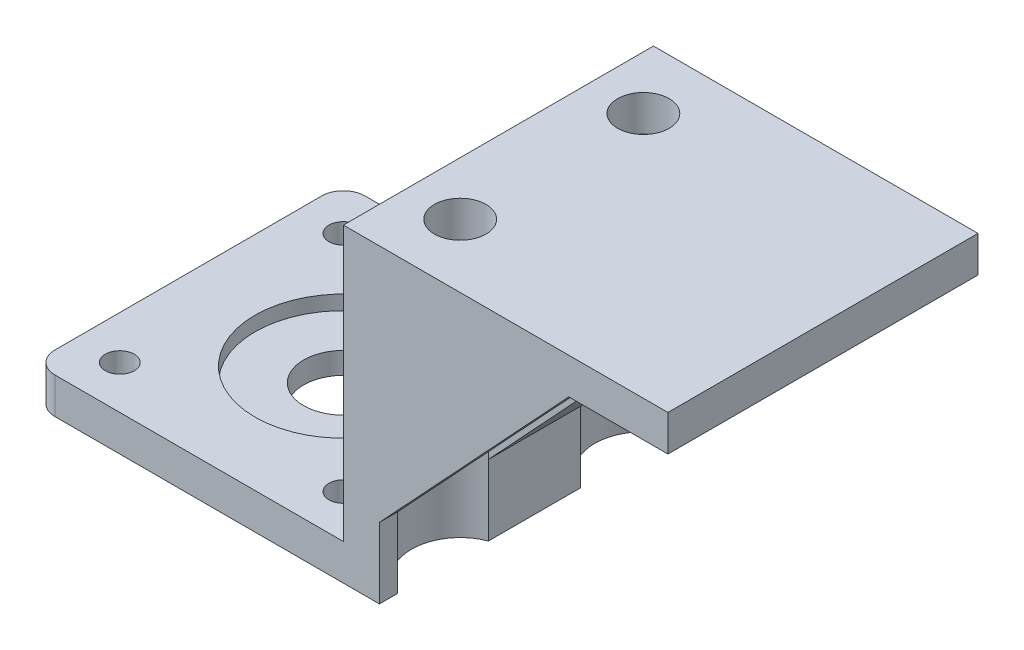
from build123d import *

# Parameters (mm, degrees)
SKETCH1_W                 = 43
SKETCH1_H                 = 43
BOSS_EXTRUDE1_DEPTH       = 5
FILLET1_R                 = 3
F_4_0MM_DOWEL_HOLE1_D     = 4
F_4_0MM_DOWEL_HOLE1_DEPTH = 10
F_4_0MM_DOWEL_HOLE1_TIP   = 1.201721238
SKETCH5_R                 = 5.5
CUT_EXTRUDE1_DEPTH        = 5
SKETCH6_W                 = 5
SKETCH6_H                 = 43
BOSS_EXTRUDE2_DEPTH       = 38
BOSS_EXTRUDE2_DEPTH_BACK  = 5
CUT_EXTRUDE4_START        = -5
SKETCH11_R                = 12.25
CUT_EXTRUDE4_DEPTH        = 2
SKETCH12_W                = 43
SKETCH12_H                = 5
BOSS_EXTRUDE3_DEPTH       = 40
SKETCH13_R                = 3.571875
CUT_EXTRUDE5_DEPTH        = 10
SKETCH15_R                = 6.75
CUT_EXTRUDE6_DEPTH        = 38
BOSS_EXTRUDE4_DEPTH       = 2.5
LPATTERN1_COUNT           = 3
LPATTERN1_PITCH           = 20.25
BOSS_EXTRUDE5_DEPTH       = 5.141078
BOSS_EXTRUDE5_DEPTH_BACK  = 7.641078
BOSS_EXTRUDE6_DEPTH       = 5


with BuildPart() as part:
    # Sketch1 → Boss-Extrude1 (new body)
    with BuildSketch(Plane(origin=(0, 0, 0), x_dir=(1, 0, 0), z_dir=(0, 1, 0))):
        with Locations((21.5, -22.047500095)):
            Rectangle(SKETCH1_W, SKETCH1_H)
    extrude(amount=BOSS_EXTRUDE1_DEPTH)

    # Fillet1
    fillet1_edges = [part.edges().sort_by_distance(p)[0] for p in [
        (0, 2.5, 0.547500095),
        (0, 2.5, 43.547500095),
    ]]
    fillet(fillet1_edges, radius=FILLET1_R)

    # Ø4.0mm Dowel Hole1
    with Locations(Plane(origin=(0, 5, 0), x_dir=(1, 0, 0), z_dir=(0, 1, 0))):
        with Locations((6, -6.547500095), (37, -6.547500095), (37, -37.547500095), (6, -37.547500095)):
            Hole(F_4_0MM_DOWEL_HOLE1_D / 2, depth=F_4_0MM_DOWEL_HOLE1_DEPTH)
            with Locations((0, 0, -(F_4_0MM_DOWEL_HOLE1_DEPTH + F_4_0MM_DOWEL_HOLE1_TIP / 2))):  # 118° drill point
                Cone(0, F_4_0MM_DOWEL_HOLE1_D / 2, F_4_0MM_DOWEL_HOLE1_TIP, mode=Mode.SUBTRACT)

    # Sketch5 → Cut-Extrude1 (cut)
    with BuildSketch(Plane(origin=(0, 5, 0), x_dir=(1, 0, 0), z_dir=(0, 1, 0))):
        with Locations((21.939339828, -22.486839923)):
            Circle(SKETCH5_R)
    extrude(amount=-CUT_EXTRUDE1_DEPTH, mode=Mode.SUBTRACT)

    # Sketch6 → Boss-Extrude2 (add, two sides)
    with BuildSketch(Plane(origin=(0, 5, 0), x_dir=(1, 0, 0), z_dir=(0, 1, 0))) as boss_extrude2_sk:
        with Locations((45.5, -22.047500095)):
            Rectangle(SKETCH6_W, SKETCH6_H)
    extrude(amount=BOSS_EXTRUDE2_DEPTH)
    extrude(boss_extrude2_sk.sketch, amount=-BOSS_EXTRUDE2_DEPTH_BACK)

    # Sketch11 → Cut-Extrude4 (cut)
    with BuildSketch(Plane.XZ.offset(CUT_EXTRUDE4_START)):
        with Locations((21.939339828, 22.486839923)):
            Circle(SKETCH11_R)
    extrude(amount=CUT_EXTRUDE4_DEPTH, mode=Mode.SUBTRACT)

    # Sketch12 → Boss-Extrude3 (add)
    with BuildSketch(Plane(origin=(48, 0, 0), x_dir=(0, 0, -1), z_dir=(1, 0, 0))):
        with Locations((-22.047500095, 40.5)):
            Rectangle(SKETCH12_W, SKETCH12_H)
    extrude(amount=BOSS_EXTRUDE3_DEPTH)

    # Sketch13 → Cut-Extrude5 (cut)
    with BuildSketch(Plane(origin=(0, 38, 0), x_dir=(-1, 0, 0), z_dir=(0, -1, 0))):
        with Locations((-50.4, -9.347500095)):
            Circle(SKETCH13_R)
        with Locations((-50.4, -34.747500095)):
            Circle(SKETCH13_R)
    extrude(amount=-CUT_EXTRUDE5_DEPTH, mode=Mode.SUBTRACT)

    # Sketch15 → Cut-Extrude6 (cut)
    with BuildSketch(Plane.XZ.offset(-38)):
        with Locations((50.4, 9.347500095)):
            Circle(SKETCH15_R)
        with Locations((50.4, 34.747500095)):
            Circle(SKETCH15_R)
    extrude(amount=CUT_EXTRUDE6_DEPTH, mode=Mode.SUBTRACT)

    # Sketch16 → Boss-Extrude4 (add)
    with BuildSketch(Plane(origin=(0, 0, 0.547500095), x_dir=(-1, 0, 0), z_dir=(0, 0, -1))):
        Polygon((-48, 9.800798491), (-74.261330934, 38), (-48, 38), align=None)
    boss_extrude4 = extrude(amount=-BOSS_EXTRUDE4_DEPTH)

    # LPattern1: Boss-Extrude4 ×3
    with Locations(*[(0, 0, i * LPATTERN1_PITCH) for i in range(1, LPATTERN1_COUNT)]):
        add(boss_extrude4)

    # Sketch18 → Boss-Extrude5 (add, two sides)
    with BuildSketch(Plane(origin=(0, 0, 20.797500095), x_dir=(-1, 0, 0), z_dir=(0, 0, -1))) as boss_extrude5_sk:
        Polygon((-48, 38), (-48, 9.800798491), (-74.261330934, 38), align=None)
    extrude(amount=BOSS_EXTRUDE5_DEPTH)
    extrude(boss_extrude5_sk.sketch, amount=-BOSS_EXTRUDE5_DEPTH_BACK)

    # Sketch19 → Boss-Extrude6 (add)
    with BuildSketch(Plane(origin=(0, 0, 0), x_dir=(-1, 0, 0), z_dir=(0, -1, 0))):
        Polygon((-15, 5.802499905), (-36, 5.802499905), (-36, -0.547500095), (-41, -0.547500095), (-41, 10.802499905), (-10, 10.802499905), (-10, -0.547500095), (-15, -0.547500095), align=None)
    extrude(amount=-BOSS_EXTRUDE6_DEPTH)


solid = part.part
